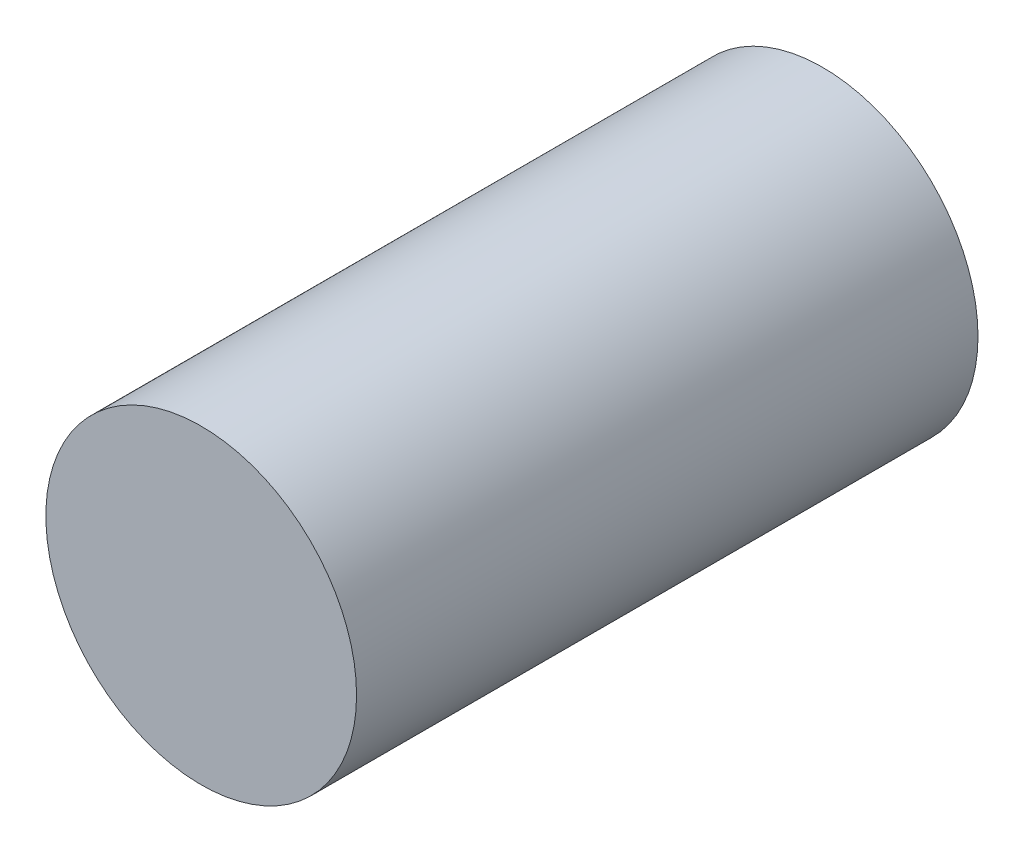
from build123d import *

# Parameters (mm, degrees)
SKETCH1_R           = 8.5
BOSS_EXTRUDE1_DEPTH = 34


with BuildPart() as part:
    # Sketch1 → Boss-Extrude1 (new body)
    with BuildSketch(Plane.XY):
        Circle(SKETCH1_R)
    extrude(amount=BOSS_EXTRUDE1_DEPTH)


solid = part.part
